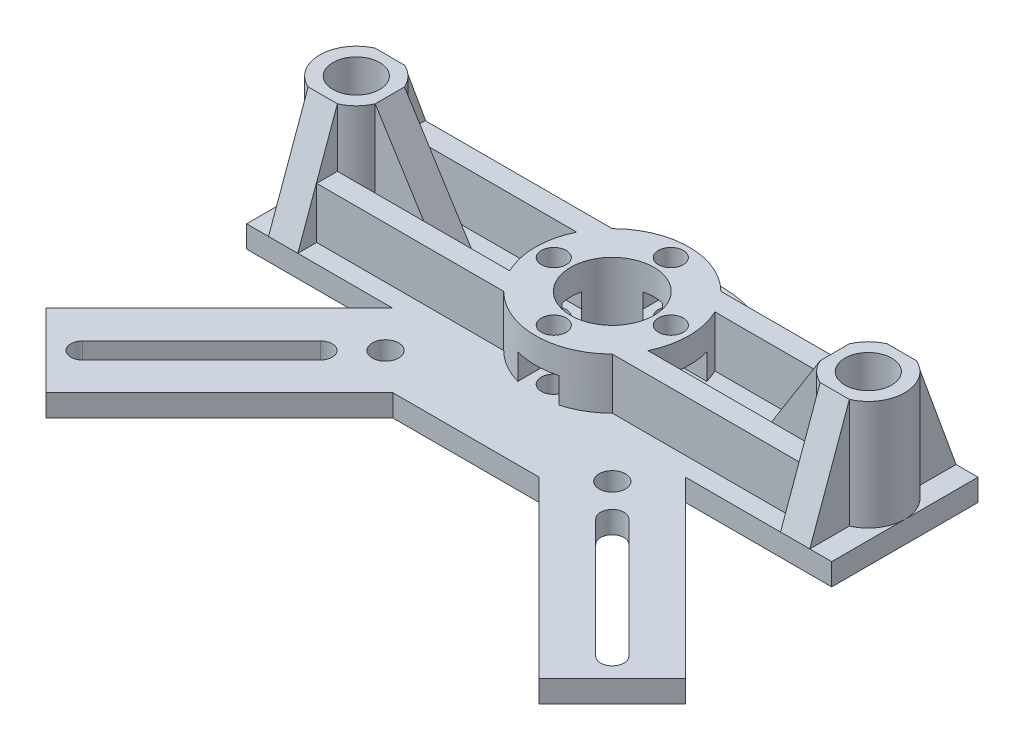
from build123d import *

# Parameters (mm, degrees)
SKETCH_1_R          = 3.2
SKETCH_1_R_2        = 1.8
SKETCH_1_R_3        = 5.7
SKETCH_1_R_4        = 1.7
EXTRUDE_1_DEPTH     = 3
SKETCH_2_R          = 10.5
EXTRUDE_2_DEPTH     = 7
SKETCH_4_R          = 1.7
CUT_EXTRUDE_1_DEPTH = 7
CUT_EXTRUDE_2_DEPTH = 3.5
SKETCH_6_R          = 5.7
CUT_EXTRUDE_3_DEPTH = 20
SKETCH_7_R          = 5
SKETCH_7_R_2        = 3.2
EXTRUDE_3_DEPTH     = 15
SKETCH_8_W          = 10
SKETCH_8_H          = 4
SKETCH_8_W_2        = 4
SKETCH_8_H_2        = 6
EXTRUDE_4_DEPTH     = 15
CUT_EXTRUDE_4_DEPTH = 15
CUT_EXTRUDE_5_DEPTH = 15
CUT_EXTRUDE_6_DEPTH = 15
SKETCH_12_W         = 25.575378798
SKETCH_12_H         = 2.842045507
EXTRUDE_5_DEPTH     = 7


with BuildPart() as part:
    # 草图1 → 凸台-拉伸1 (new body)
    with BuildSketch(Plane(origin=(0, 0, 0), x_dir=(1, 0, 0), z_dir=(0, 1, 0))):
        with BuildLine():
            Line((-35.081832586, -10), (-40, -10))
            Line((-40, -10), (-40, 10))
            Line((-40, 10), (-11.180339887, 10))
            ThreePointArc((-11.180339887, 10), (0, 15), (11.180339887, 10))
            Line((11.180339887, 10), (40, 10))
            Line((40, 10), (40, -10))
            Line((40, -10), (20, -10))
            Line((20, -10), (43.844622395, -33.844622395))
            Line((43.844622395, -33.844622395), (33.844622395, -43.844622395))
            Line((33.844622395, -43.844622395), (10, -20))
            Line((10, -20), (-10, -20))
            Line((-10, -20), (-33.713203436, -43.713203436))
            Line((-33.713203436, -43.713203436), (-43.713203436, -33.713203436))
            Line((-43.713203436, -33.713203436), (-20, -10))
            Line((-20, -10), (-35.081832586, -10))
        make_face()
        with Locations((35, 0)):
            Circle(SKETCH_1_R, mode=Mode.SUBTRACT)
        with Locations((-15.5, -15.5)):
            Circle(SKETCH_1_R_2, mode=Mode.SUBTRACT)
        with Locations((15.5, -15.5)):
            Circle(SKETCH_1_R_2, mode=Mode.SUBTRACT)
        with Locations((-35, 0)):
            Circle(SKETCH_1_R, mode=Mode.SUBTRACT)
        Circle(SKETCH_1_R_3, mode=Mode.SUBTRACT)
        with Locations((-8, 0)):
            Circle(SKETCH_1_R_4, mode=Mode.SUBTRACT)
        with Locations((0, 8)):
            Circle(SKETCH_1_R_4, mode=Mode.SUBTRACT)
        with Locations((8, 0)):
            Circle(SKETCH_1_R_4, mode=Mode.SUBTRACT)
        with Locations((0, -8)):
            Circle(SKETCH_1_R_4, mode=Mode.SUBTRACT)
        with BuildLine():
            Line((-18.818376618, -21.081118318), (-35.081832586, -37.344574285))
            ThreePointArc((-35.081832586, -37.344574285), (-37.344574285, -37.344574285), (-37.344574285, -35.081832586))
            Line((-37.344574285, -35.081832586), (-21.081118318, -18.818376618))
            ThreePointArc((-21.081118318, -18.818376618), (-18.818376618, -18.818376618), (-18.818376618, -21.081118318))
        make_face(mode=Mode.SUBTRACT)
        with BuildLine():
            Line((21.081118316, -18.818376616), (37.344574284, -35.081832584))
            ThreePointArc((37.344574284, -35.081832584), (37.344574284, -37.344574284), (35.081832584, -37.344574284))
            Line((35.081832584, -37.344574284), (18.818376616, -21.081118316))
            ThreePointArc((18.818376616, -21.081118316), (18.818376616, -18.818376616), (21.081118316, -18.818376616))
        make_face(mode=Mode.SUBTRACT)
    extrude(amount=EXTRUDE_1_DEPTH)

    # 草图2 → 凸台-拉伸2 (add)
    with BuildSketch(Plane(origin=(0, 3, 0), x_dir=(1, 0, 0), z_dir=(0, 1, 0))):
        Circle(SKETCH_2_R)
    extrude(amount=EXTRUDE_2_DEPTH)

    # 草图4 → 切除-拉伸1 (cut)
    with BuildSketch(Plane.XZ.offset(-3)):
        with Locations((0, -8)):
            Circle(SKETCH_4_R)
        with Locations((-8, 0)):
            Circle(SKETCH_4_R)
        with Locations((8, 0)):
            Circle(SKETCH_4_R)
        with Locations((0, 8)):
            Circle(SKETCH_4_R)
    extrude(amount=-CUT_EXTRUDE_1_DEPTH, mode=Mode.SUBTRACT)

    # 草图5 → 切除-拉伸2 (cut)
    with BuildSketch(Plane(origin=(0, 3, 0), x_dir=(1, 0, 0), z_dir=(0, 1, 0))):
        Polygon((-4.766838493, 0), (-6.383419246, 2.8), (-11.233161507, 2.8), (-11.233161507, -2.8), (-6.383419246, -2.8), align=None)
        Polygon((4.766838493, 0), (6.383419246, -2.8), (11.233161507, -2.8), (11.233161507, 2.8), (6.383419246, 2.8), align=None)
        Polygon((-2.8, 11.233161507), (-2.8, 6.383419246), (0, 4.766838493), (2.8, 6.383419246), (2.8, 11.233161507), align=None)
        Polygon((0, -4.766838493), (-2.8, -6.383419246), (-2.8, -11.233161507), (2.8, -11.233161507), (2.8, -6.383419246), align=None)
    extrude(amount=CUT_EXTRUDE_2_DEPTH, mode=Mode.SUBTRACT)

    # 草图6 → 切除-拉伸3 (cut)
    with BuildSketch(Plane.XZ.offset(-3)):
        Circle(SKETCH_6_R)
    extrude(amount=-CUT_EXTRUDE_3_DEPTH, mode=Mode.SUBTRACT)

    # 草图7 → 凸台-拉伸3 (add)
    with BuildSketch(Plane(origin=(0, 3, 0), x_dir=(1, 0, 0), z_dir=(0, 1, 0))):
        with Locations((-35, 0)):
            Circle(SKETCH_7_R)
        with Locations((-35, 0)):
            Circle(SKETCH_7_R_2, mode=Mode.SUBTRACT)
        with Locations((35, 0)):
            Circle(SKETCH_7_R)
        with Locations((35, 0)):
            Circle(SKETCH_7_R_2, mode=Mode.SUBTRACT)
    extrude(amount=EXTRUDE_3_DEPTH)

    # 草图8 → 凸台-拉伸4 (add)
    with BuildSketch(Plane(origin=(0, 3, 0), x_dir=(1, 0, 0), z_dir=(0, 1, 0))):
        with Locations((-26, 0)):
            Rectangle(SKETCH_8_W, SKETCH_8_H)
        with Locations((-35, 7)):
            Rectangle(SKETCH_8_W_2, SKETCH_8_H_2)
        with Locations((-35, -7)):
            Rectangle(SKETCH_8_W_2, SKETCH_8_H_2)
        with Locations((26, 0)):
            Rectangle(SKETCH_8_W, SKETCH_8_H)
        with Locations((35, 7)):
            Rectangle(SKETCH_8_W_2, SKETCH_8_H_2)
        with Locations((35, -7)):
            Rectangle(SKETCH_8_W_2, SKETCH_8_H_2)
    extrude(amount=EXTRUDE_4_DEPTH)

    # 草图9 → 切除-拉伸4 (cut)
    with BuildSketch(Plane.XY.offset(2)):
        Polygon((-30.417424305, 18), (-21, 3), (-21, 18), align=None)
        Polygon((21, 3), (30.417424305, 18), (21, 18), align=None)
    extrude(amount=-CUT_EXTRUDE_4_DEPTH, mode=Mode.SUBTRACT)

    # 草图10 → 切除-拉伸5 (cut)
    with BuildSketch(Plane.ZY.offset(-33)):
        Polygon((-4.582575695, 18), (-10, 3), (-10, 18), align=None)
        Polygon((4.582575695, 18), (10, 18), (10, 3), align=None)
    extrude(amount=-CUT_EXTRUDE_5_DEPTH, mode=Mode.SUBTRACT)

    # 草图11 → 切除-拉伸6 (cut)
    with BuildSketch(Plane(origin=(-33, 0, 0), x_dir=(0, 0, -1), z_dir=(1, 0, 0))):
        Polygon((-4.582575695, 18), (-10, 3), (-10, 18), align=None)
        Polygon((4.582575695, 18), (10, 3), (10, 18), align=None)
    extrude(amount=-CUT_EXTRUDE_6_DEPTH, mode=Mode.SUBTRACT)

    # 草图12 → 凸台-拉伸5 (add)
    with BuildSketch(Plane(origin=(0, 3, 0), x_dir=(1, 0, 0), z_dir=(0, 1, 0))):
        with Locations((-20.212310601, -6.003598449)):
            Rectangle(SKETCH_12_W, SKETCH_12_H)
        with Locations((-20.212310601, 6.003598449)):
            Rectangle(SKETCH_12_W, SKETCH_12_H)
        with Locations((20.212310601, 6.003598449)):
            Rectangle(SKETCH_12_W, SKETCH_12_H)
        with Locations((20.212310601, -6.003598449)):
            Rectangle(SKETCH_12_W, SKETCH_12_H)
    extrude(amount=EXTRUDE_5_DEPTH)


solid = part.part
